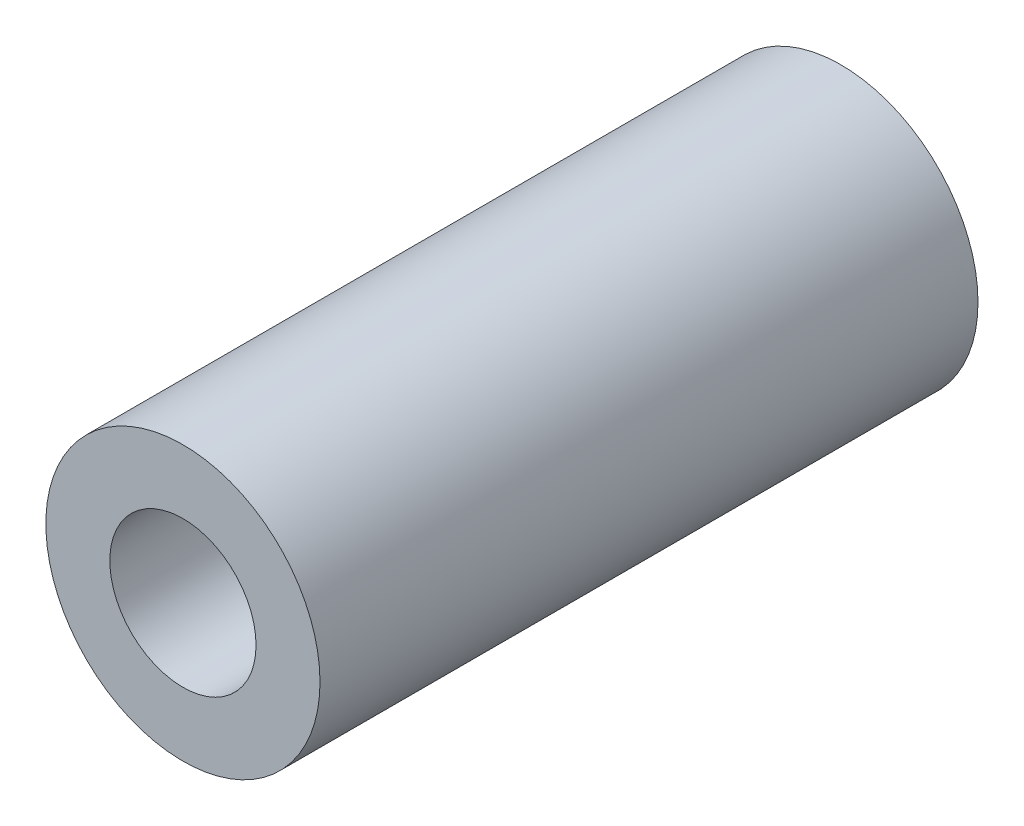
from build123d import *

# Parameters (mm, degrees)
SKETCH1_R           = 3.75
SKETCH1_R_2         = 2.00000381
BOSS_EXTRUDE1_DEPTH = 18


with BuildPart() as part:
    # Sketch1 → Boss-Extrude1 (new body)
    with BuildSketch(Plane.XY.offset(73.33537242)):
        with Locations((-17.900817576, 104.015877234)):
            Circle(SKETCH1_R)
        with Locations((-17.900817576, 104.015877234)):
            Circle(SKETCH1_R_2, mode=Mode.SUBTRACT)
    extrude(amount=BOSS_EXTRUDE1_DEPTH)


solid = part.part
